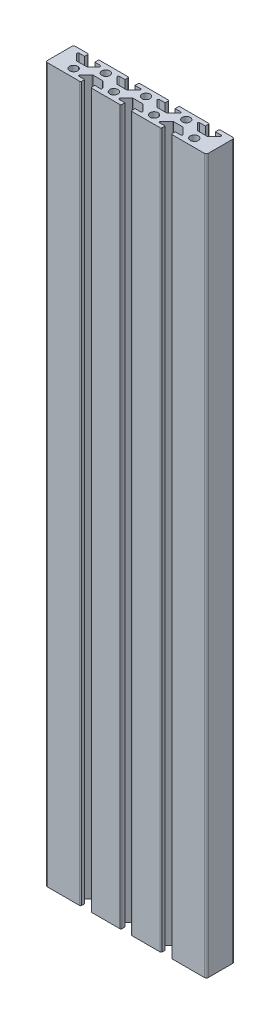
from build123d import *

# Parameters (mm, degrees)
SKETCH1_R           = 2
BOSS_EXTRUDE1_DEPTH = 355
FILLET1_R           = 0.5
FILLET2_R           = 0.5
FILLET3_R           = 1
SKETCH2_R           = 2.5
CUT_EXTRUDE2_DEPTH  = 230
SKETCH3_R           = 5.5
CUT_EXTRUDE3_DEPTH  = 7
SKETCH4_R           = 2.5
CUT_EXTRUDE4_DEPTH  = 7
SKETCH5_R           = 5.5
CUT_EXTRUDE5_DEPTH  = 7


with BuildPart() as part:
    # Sketch1 → Boss-Extrude1 (new body)
    with BuildSketch(Plane(origin=(0, 0, 0), x_dir=(1, 0, 0), z_dir=(0, 1, 0))):
        Polygon((67.5, 8), (63.5, 12), (67.5, 12), (67.5, 14), (52.5, 14), (52.5, 12), (56.5, 12), (52.5, 8), (47.5, 8), (43.5, 12), (47.5, 12), (47.5, 14), (32.5, 14), (32.5, 12), (36.5, 12), (32.5, 8), (27.5, 8), (23.5, 12), (27.5, 12), (27.5, 14), (12.5, 14), (12.5, 12), (16.5, 12), (12.5, 8), (7.5, 8), (3.5, 12), (7.5, 12), (7.5, 14), (0, 14), (0, 0), (17.5, 0), (17.5, 2), (13.5, 2), (17.5, 6), (22.5, 6), (26.5, 2), (22.5, 2), (22.5, 0), (37.5, 0), (37.5, 2), (33.5, 2), (37.5, 6), (42.5, 6), (46.5, 2), (42.5, 2), (42.5, 0), (57.5, 0), (57.5, 2), (53.5, 2), (57.5, 6), (62.5, 6), (66.5, 2), (62.5, 2), (62.5, 0), (80, 0), (80, 14), (72.5, 14), (72.5, 12), (76.5, 12), (72.5, 8), align=None)
        with Locations((10, 4)):
            Circle(SKETCH1_R, mode=Mode.SUBTRACT)
        with Locations((30, 4)):
            Circle(SKETCH1_R, mode=Mode.SUBTRACT)
        with Locations((50, 4)):
            Circle(SKETCH1_R, mode=Mode.SUBTRACT)
        with Locations((70, 4)):
            Circle(SKETCH1_R, mode=Mode.SUBTRACT)
        with Locations((20, 10)):
            Circle(SKETCH1_R, mode=Mode.SUBTRACT)
        with Locations((40, 10)):
            Circle(SKETCH1_R, mode=Mode.SUBTRACT)
        with Locations((60, 10)):
            Circle(SKETCH1_R, mode=Mode.SUBTRACT)
    extrude(amount=BOSS_EXTRUDE1_DEPTH)

    # Fillet1
    fillet1_edges = [part.edges().sort_by_distance(p)[0] for p in [
        (7.5, 177.5, -14),
        (3.5, 177.5, -12),
        (7.5, 177.5, -8),
        (12.5, 177.5, -8),
        (16.5, 177.5, -12),
        (12.5, 177.5, -14),
        (27.5, 177.5, -14),
        (23.5, 177.5, -12),
        (27.5, 177.5, -8),
        (32.5, 177.5, -8),
        (36.5, 177.5, -12),
        (32.5, 177.5, -14),
        (47.5, 177.5, -14),
        (43.5, 177.5, -12),
        (47.5, 177.5, -8),
        (52.5, 177.5, -8),
        (56.5, 177.5, -12),
        (52.5, 177.5, -14),
        (67.5, 177.5, -14),
        (63.5, 177.5, -12),
        (67.5, 177.5, -8),
        (72.5, 177.5, -8),
        (76.5, 177.5, -12),
        (72.5, 177.5, -14),
    ]]
    fillet(fillet1_edges, radius=FILLET1_R)

    # Fillet2
    fillet2_edges = [part.edges().sort_by_distance(p)[0] for p in [
        (26.5, 177.5, -2),
        (22.5, 177.5, -6),
        (17.5, 177.5, -6),
        (13.5, 177.5, -2),
        (17.5, 177.5, 0),
        (62.5, 177.5, 0),
        (66.5, 177.5, -2),
        (62.5, 177.5, -6),
        (57.5, 177.5, -6),
        (53.5, 177.5, -2),
        (57.5, 177.5, 0),
        (42.5, 177.5, 0),
        (46.5, 177.5, -2),
        (42.5, 177.5, -6),
        (37.5, 177.5, -6),
        (33.5, 177.5, -2),
        (37.5, 177.5, 0),
        (22.5, 177.5, 0),
    ]]
    fillet(fillet2_edges, radius=FILLET2_R)

    # Fillet3
    fillet3_edges = [part.edges().sort_by_distance(p)[0] for p in [
        (0, 177.5, 0),
        (0, 177.5, -14),
        (80, 177.5, -14),
        (80, 177.5, 0),
    ]]
    fillet(fillet3_edges, radius=FILLET3_R)

    # Sketch2 → Cut-Extrude2 (cut)
    with BuildSketch(Plane(origin=(0, 0, -14), x_dir=(-1, 0, 0), z_dir=(0, 0, -1))):
        with Locations((-40, 10)):
            Circle(SKETCH2_R)
    extrude(amount=-CUT_EXTRUDE2_DEPTH, mode=Mode.SUBTRACT)

    # Sketch3 → Cut-Extrude3 (cut)
    with BuildSketch(Plane(origin=(0, 0, -14), x_dir=(-1, 0, 0), z_dir=(0, 0, -1))):
        with Locations((-40, 10)):
            Circle(SKETCH3_R)
    extrude(amount=-CUT_EXTRUDE3_DEPTH, mode=Mode.SUBTRACT)

    # Sketch4 → Cut-Extrude4 (cut)
    with BuildSketch(Plane(origin=(0, 0, -14), x_dir=(-1, 0, 0), z_dir=(0, 0, -1))):
        with Locations((-40, 345)):
            Circle(SKETCH4_R)
    extrude(amount=-CUT_EXTRUDE4_DEPTH, mode=Mode.SUBTRACT)

    # Sketch5 → Cut-Extrude5 (cut)
    with BuildSketch(Plane(origin=(0, 0, -14), x_dir=(-1, 0, 0), z_dir=(0, 0, -1))):
        with Locations((-40, 345)):
            Circle(SKETCH5_R)
    extrude(amount=-CUT_EXTRUDE5_DEPTH, mode=Mode.SUBTRACT)


solid = part.part
